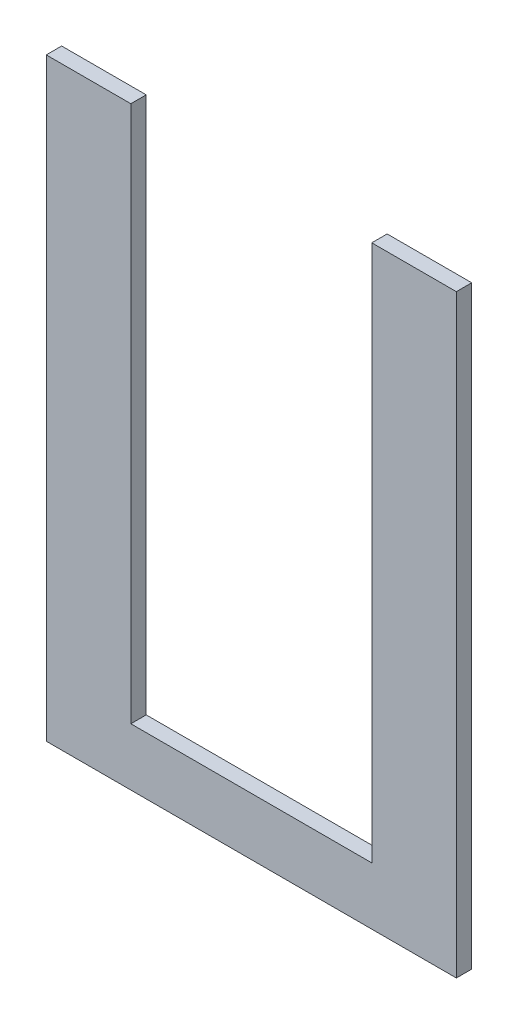
from build123d import *

# Parameters (mm, degrees)
BOSS_EXTRUDE1_DEPTH = 3


with BuildPart() as part:
    # Sketch1 → Boss-Extrude1 (new body)
    with BuildSketch(Plane.XY):
        Polygon((16.5, 115.957009142), (16.5, 11.2), (63.5, 11.2), (63.5, 115.957009142), (80, 115.957009142), (80, 0), (0, 0), (0, 115.957009142), align=None)
    extrude(amount=-BOSS_EXTRUDE1_DEPTH)


solid = part.part
